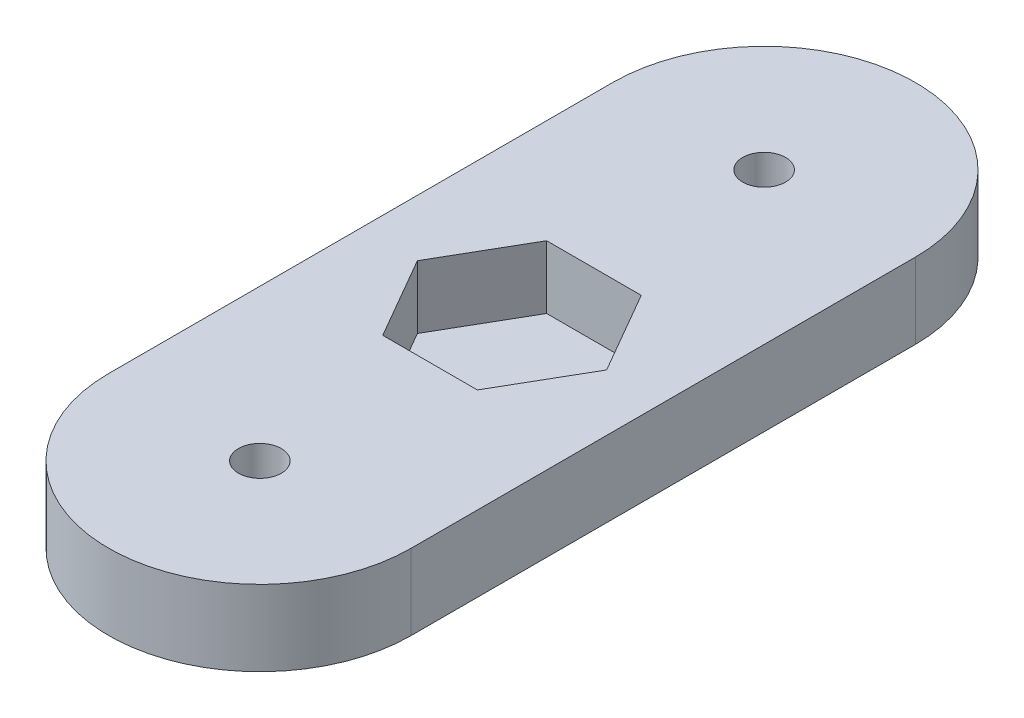
from build123d import *

# Parameters (mm, degrees)
SKETCH1_R           = 1.7
BOSS_EXTRUDE1_DEPTH = 6
CUT_EXTRUDE1_DEPTH  = 5


with BuildPart() as part:
    # Sketch1 → Boss-Extrude1 (new body)
    with BuildSketch(Plane(origin=(0, 0, 0), x_dir=(1, 0, 0), z_dir=(0, 1, 0))):
        with BuildLine():
            Line((-12, 0), (-12, 40))
            ThreePointArc((-12, 40), (0, 52), (12, 40))
            Line((12, 40), (12, 0))
            ThreePointArc((12, 0), (0, -12), (-12, 0))
        make_face()
        with Locations((0, 40)):
            Circle(SKETCH1_R, mode=Mode.SUBTRACT)
        Circle(SKETCH1_R, mode=Mode.SUBTRACT)
    extrude(amount=BOSS_EXTRUDE1_DEPTH)

    # Sketch2 → Cut-Extrude1 (cut)
    with BuildSketch(Plane(origin=(0, 6, 0), x_dir=(1, 0, 0), z_dir=(0, 1, 0))):
        Polygon((3.75277675, 13.5), (7.505553499, 20), (3.75277675, 26.5), (-3.75277675, 26.5), (-7.505553499, 20), (-3.75277675, 13.5), align=None)
    extrude(amount=-CUT_EXTRUDE1_DEPTH, mode=Mode.SUBTRACT)


solid = part.part
